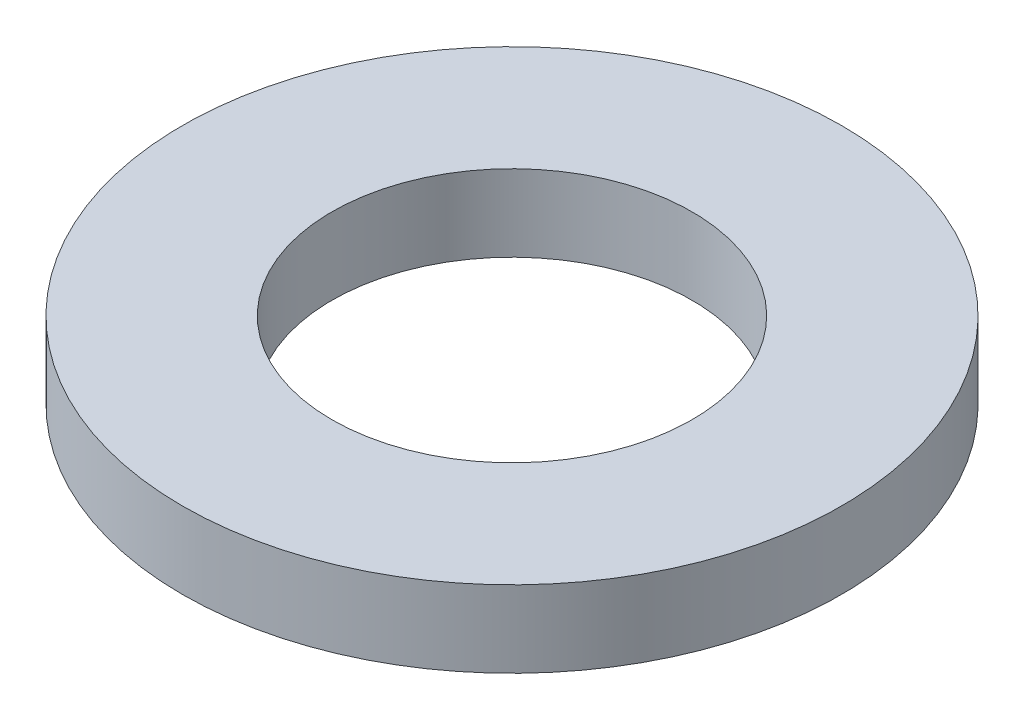
from build123d import *

# Parameters (mm, degrees)
SKETCH1_R           = 2.1844
SKETCH1_R_2         = 1.1938
BOSS_EXTRUDE1_DEPTH = 0.508


with BuildPart() as part:
    # Sketch1 → Boss-Extrude1 (new body)
    with BuildSketch(Plane(origin=(0, 0, 0), x_dir=(1, 0, 0), z_dir=(0, 1, 0))):
        with Locations(Location((0, 0, 0), (0, 0, 270))):  # turned: the seam where the file's is
            Circle(SKETCH1_R)
        with Locations(Location((0, 0, 0), (0, 0, 270))):  # turned: the seam where the file's is
            Circle(SKETCH1_R_2, mode=Mode.SUBTRACT)
    extrude(amount=BOSS_EXTRUDE1_DEPTH)


solid = part.part
